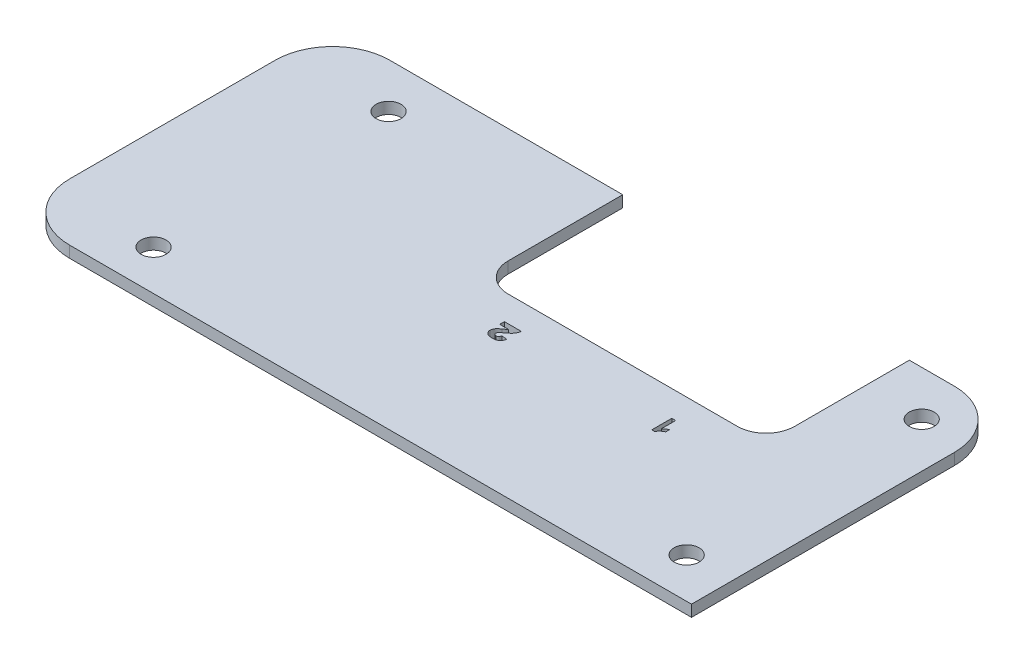
from build123d import *

# Parameters (mm, degrees)
CROQUIS1_R              = 2.175
SALIENTE_EXTRUIR1_DEPTH = 2
CROQUIS2_W              = 50
CROQUIS2_H              = 25
CORTAR_EXTRUIR1_DEPTH   = 2
REDONDEO1_R             = 5
CORTAR_EXTRUIR2_DEPTH   = 2


with BuildPart() as part:
    # Croquis1 → Saliente-Extruir1 (new body)
    with BuildSketch(Plane(origin=(0, 0, 0), x_dir=(1, 0, 0), z_dir=(0, 1, 0))):
        with BuildLine():
            Line((-59.24665691, 17.931526281), (-59.24665691, -17.931526281))
            ThreePointArc((-59.24665691, -17.931526281), (-56.317724722, -25.002594093), (-49.24665691, -27.931526281))
            Line((-49.24665691, -27.931526281), (-31.500611182, -27.931526281))
            Line((-31.500611182, -27.931526281), (37.914147183, -27.931526281))
            Line((37.914147183, -27.931526281), (59.24665691, -27.931526281))
            Line((59.24665691, -27.931526281), (59.24665691, 17.931526281))
            ThreePointArc((59.24665691, 17.931526281), (56.317724722, 25.002594093), (49.24665691, 27.931526281))
            Line((49.24665691, 27.931526281), (-49.24665691, 27.931526281))
            ThreePointArc((-49.24665691, 27.931526281), (-56.317724722, 25.002594093), (-59.24665691, 17.931526281))
        make_face()
        with Locations((51.3850757, -20.916819625)):
            Circle(CROQUIS1_R, mode=Mode.SUBTRACT)
        with Locations((-41.6149243, -20.916819625)):
            Circle(CROQUIS1_R, mode=Mode.SUBTRACT)
        with Locations((-41.6149243, 20.083180375)):
            Circle(CROQUIS1_R, mode=Mode.SUBTRACT)
        with Locations((51.3850757, 20.083180375)):
            Circle(CROQUIS1_R, mode=Mode.SUBTRACT)
    extrude(amount=SALIENTE_EXTRUIR1_DEPTH)

    # Croquis2 → Cortar-Extruir1 (cut)
    with BuildSketch(Plane(origin=(0, 2, 0), x_dir=(1, 0, 0), z_dir=(0, 1, 0))):
        with Locations((16.3850757, 15.431526281)):
            Rectangle(CROQUIS2_W, CROQUIS2_H)
    extrude(amount=-CORTAR_EXTRUIR1_DEPTH, mode=Mode.SUBTRACT)

    # Redondeo1
    redondeo1_edges = [part.edges().sort_by_distance(p)[0] for p in [
        (41.3850757, 1, -2.931526281),
        (-8.6149243, 1, -2.931526281),
    ]]
    fillet(redondeo1_edges, radius=REDONDEO1_R)

    # Croquis4 → Cortar-Extruir2 (cut)
    with BuildSketch(Plane.XZ):
        with BuildLine():
            Line((29.444521437, 1.568473719), (30.11759836, 1.568473719))
            Line((30.11759836, 1.568473719), (30.11759836, 4.060260578))
            add(Edge.make_bspline(
                [(30.11759836, 4.060260578), (30.148105822, 4.029289813), (30.208706879, 3.967768435), (30.305496315, 3.881954316), (30.405978505, 3.802124559), (30.511147814, 3.729037402), (30.61962941, 3.661651481), (30.732531913, 3.600498497), (30.849036967, 3.544732313), (30.929745062, 3.513567679), (30.970162463, 3.497960898)],
                knots=[0, 0, 0, 0, 0.000130388, 0.000259007, 0.000387777, 0.000515175, 0.000643004, 0.000770695, 0.000900222, 0.001030157, 0.001030157, 0.001030157, 0.001030157], degree=3))
            Line((30.970162463, 3.497960898), (30.970162463, 4.171037821))
            add(Edge.make_bspline(
                [(30.970162463, 4.171037821), (30.925337531, 4.187845247), (30.831522436, 4.223021882), (30.693082905, 4.297844367), (30.548583301, 4.390482153), (30.427195385, 4.481338367), (30.33081837, 4.562116803), (30.263458163, 4.62704999), (30.201045059, 4.693544942), (30.145925041, 4.763747872), (30.096651183, 4.836239432), (30.052992396, 4.910901194), (30.014562629, 4.987969009), (29.994444914, 5.041637327), (29.984385219, 5.068473719)],
                knots=[0, 0, 0, 0, 0.000143475, 0.000300282, 0.000470852, 0.000658192, 0.000754698, 0.000847923, 0.000938715, 0.001028066, 0.00111538, 0.001201478, 0.001287394, 0.001373323, 0.001373323, 0.001373323, 0.001373323], degree=3))
            Line((29.984385219, 5.068473719), (29.444521437, 5.068473719))
            Line((29.444521437, 5.068473719), (29.444521437, 1.568473719))
        make_face()
        with BuildLine():
            Line((0.238227731, 1.568473719), (3.192773185, 1.568473719))
            add(Edge.make_bspline(
                [(3.192773185, 1.568473719), (3.188115357, 1.604788367), (3.178835808, 1.677136155), (3.155068568, 1.784065443), (3.127140852, 1.889748411), (3.092461936, 1.993848095), (3.049680145, 2.095512273), (3.002856429, 2.19669015), (2.94729708, 2.295118176), (2.886860339, 2.394367373), (2.814200344, 2.493443888), (2.729582069, 2.596122101), (2.629633226, 2.701343615), (2.516505876, 2.810695804), (2.389788427, 2.923761308), (2.248649332, 3.040002632), (2.094036264, 3.160927698), (1.984462278, 3.240458026), (1.927858413, 3.281541901)],
                knots=[0, 0, 0, 0, 0.000109782, 0.000218714, 0.000328285, 0.000437662, 0.000547529, 0.000659044, 0.000771901, 0.000886408, 0.001007447, 0.001140123, 0.001285331, 0.001442542, 0.001612054, 0.001794653, 0.001990995, 0.002200805, 0.002200805, 0.002200805, 0.002200805], degree=3))
            add(Edge.make_bspline(
                [(1.927858413, 3.281541901), (1.893424314, 3.306253875), (1.827407407, 3.353631569), (1.734179987, 3.424062611), (1.650525877, 3.490388277), (1.575249679, 3.550647526), (1.510130493, 3.607333231), (1.454212438, 3.658929136), (1.406754234, 3.705389161), (1.358740775, 3.761072032), (1.311519349, 3.826339302), (1.270109393, 3.904031485), (1.242851252, 3.980026103), (1.239730022, 4.031104768), (1.238227731, 4.055689628)],
                knots=[0, 0, 0, 0, 0.000127149, 0.000243769, 0.000350475, 0.000447421, 0.000533008, 0.000609403, 0.000675694, 0.000732085, 0.000829839, 0.000916571, 0.000995853, 0.001069422, 0.001069422, 0.001069422, 0.001069422], degree=3))
            add(Edge.make_bspline(
                [(1.238227731, 4.055689628), (1.239685746, 4.080972097), (1.242541207, 4.130486734), (1.266653205, 4.201654218), (1.305747651, 4.266442593), (1.359509302, 4.323756407), (1.424157163, 4.371621265), (1.498188647, 4.407383572), (1.580621178, 4.428177391), (1.638203662, 4.430771544), (1.667915231, 4.432110082)],
                knots=[0, 0, 0, 0, 7.5688e-05, 0.000148232, 0.000222776, 0.000301178, 0.00038243, 0.000462799, 0.000546343, 0.000635405, 0.000635405, 0.000635405, 0.000635405], degree=3))
            add(Edge.make_bspline(
                [(1.667915231, 4.432110082), (1.698813755, 4.430809048), (1.758278058, 4.428305203), (1.843219818, 4.407324867), (1.918981726, 4.372152378), (1.974530483, 4.331309897), (2.013689853, 4.291349515), (2.040808134, 4.255651482), (2.064355526, 4.214184875), (2.087086891, 4.168265993), (2.105602713, 4.116647385), (2.122002547, 4.059916325), (2.136216017, 3.998020881), (2.14352285, 3.954643819), (2.14731864, 3.932110082)],
                knots=[0, 0, 0, 0, 9.2602e-05, 0.000178213, 0.000260508, 0.00034176, 0.000383446, 0.000428049, 0.000475798, 0.000526305, 0.000581584, 0.000640021, 0.000703423, 0.000771966, 0.000771966, 0.000771966, 0.000771966], degree=3))
            Line((2.14731864, 3.932110082), (3.101864094, 4.006683946))
            add(Edge.make_bspline(
                [(3.101864094, 4.006683946), (3.096994116, 4.039650766), (3.087461692, 4.104179537), (3.067871533, 4.197366087), (3.046962689, 4.285499285), (3.022046312, 4.367704138), (2.994400178, 4.444545826), (2.964137877, 4.515998173), (2.929779719, 4.581157532), (2.881644848, 4.661426522), (2.810389047, 4.751759712), (2.709397011, 4.847015779), (2.592564179, 4.927953002), (2.483825815, 4.984190233), (2.388096824, 5.021729738), (2.308290198, 5.046369437), (2.221990226, 5.067601851), (2.128965037, 5.084403665), (2.029469325, 5.098056751), (1.923011653, 5.106807753), (1.810025667, 5.11265402), (1.732553843, 5.113495947), (1.692773185, 5.113928264)],
                knots=[0, 0, 0, 0, 9.995e-05, 0.000195642, 0.00028556, 0.000371615, 0.000453168, 0.000530478, 0.000604178, 0.000673972, 0.000811075, 0.000947734, 0.001089005, 0.001236077, 0.001313892, 0.001397231, 0.00148646, 0.001580349, 0.001680693, 0.001787626, 0.001900695, 0.002020032, 0.002020032, 0.002020032, 0.002020032], degree=3))
            add(Edge.make_bspline(
                [(1.692773185, 5.113928264), (1.651340679, 5.113397506), (1.570577331, 5.112362914), (1.453036045, 5.107878174), (1.34242277, 5.098420374), (1.23907833, 5.085938383), (1.142821984, 5.069686254), (1.053687032, 5.049772162), (0.971451968, 5.026806196), (0.895920672, 4.999295684), (0.825740946, 4.968820838), (0.760065932, 4.933742155), (0.698346318, 4.894802211), (0.640597303, 4.851866527), (0.586189039, 4.805657255), (0.535953343, 4.755006285), (0.488639596, 4.701098695), (0.446364968, 4.642792682), (0.408254872, 4.582011512), (0.374293308, 4.519431441), (0.347155821, 4.454387488), (0.322843456, 4.388116191), (0.305795233, 4.319440044), (0.292454011, 4.249312564), (0.285675472, 4.177270825), (0.284352217, 4.128617444), (0.283682276, 4.103985082)],
                knots=[0, 0, 0, 0, 0.000124308, 0.000242311, 0.000352782, 0.000457261, 0.000554523, 0.000645501, 0.000731157, 0.000810464, 0.000886471, 0.000960502, 0.001033604, 0.001105196, 0.001176222, 0.001247536, 0.001319026, 0.00139119, 0.001463312, 0.001534167, 0.001604484, 0.00167457, 0.001745713, 0.00181648, 0.001888563, 0.001962482, 0.001962482, 0.001962482, 0.001962482], degree=3))
            add(Edge.make_bspline(
                [(0.283682276, 4.103985082), (0.284146132, 4.077674435), (0.285072563, 4.025125751), (0.295101547, 3.947135962), (0.308857923, 3.869836073), (0.32967374, 3.793603518), (0.356890877, 3.718261121), (0.389668246, 3.643538536), (0.42798763, 3.569681371), (0.472692567, 3.496283619), (0.524647072, 3.422352303), (0.587623536, 3.348689881), (0.658047527, 3.271963933), (0.739230369, 3.194302446), (0.829692238, 3.115067123), (0.930761028, 3.035143861), (1.039488039, 2.951462642), (1.117230695, 2.897900463), (1.157261822, 2.87032031)],
                knots=[0, 0, 0, 0, 7.8886e-05, 0.000157555, 0.000235564, 0.0003143, 0.000394275, 0.000475692, 0.000558919, 0.000643695, 0.000733358, 0.000829659, 0.000934195, 0.001045703, 0.0011665, 0.001294833, 0.001432194, 0.001578003, 0.001578003, 0.001578003, 0.001578003], degree=3))
            add(Edge.make_bspline(
                [(1.157261822, 2.87032031), (1.180969807, 2.854508529), (1.226365633, 2.824232281), (1.29078794, 2.780126058), (1.349326873, 2.74020997), (1.402090118, 2.704045916), (1.448471107, 2.67109448), (1.488355102, 2.641479001), (1.522950215, 2.616823253), (1.561123658, 2.587028109), (1.606631457, 2.549422878), (1.662933813, 2.5008226), (1.723946438, 2.446547502), (1.765107013, 2.407152874), (1.786523185, 2.386655537)],
                knots=[0, 0, 0, 0, 8.549e-05, 0.000163696, 0.00023422, 0.000298049, 0.000355595, 0.000404888, 0.00044708, 0.000483022, 0.000550133, 0.000624164, 0.000706149, 0.000795075, 0.000795075, 0.000795075, 0.000795075], degree=3))
            Line((1.786523185, 2.386655537), (0.238227731, 2.386655537))
            Line((0.238227731, 2.386655537), (0.238227731, 1.568473719))
        make_face()
    extrude(amount=-CORTAR_EXTRUIR2_DEPTH, mode=Mode.SUBTRACT)


solid = part.part
